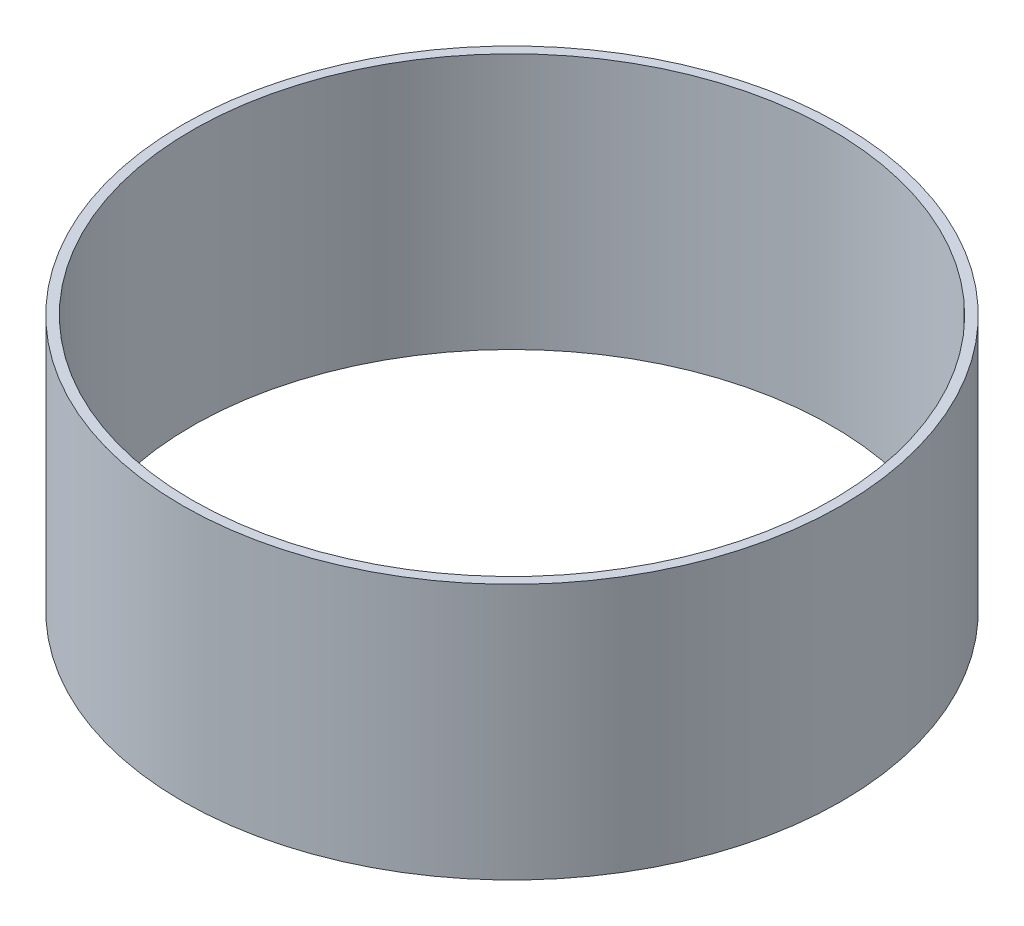
from build123d import *

# Parameters (mm, degrees)
SKETCH1_R           = 65.405
SKETCH1_R_2         = 63.5
BOSS_EXTRUDE2_DEPTH = 25.4


with BuildPart() as part:
    # Sketch1 → Boss-Extrude2 (new body, symmetric)
    with BuildSketch(Plane(origin=(0, 0, 0), x_dir=(1, 0, 0), z_dir=(0, 1, 0))):
        Circle(SKETCH1_R)
        Circle(SKETCH1_R_2, mode=Mode.SUBTRACT)
    extrude(amount=BOSS_EXTRUDE2_DEPTH, both=True)


solid = part.part
